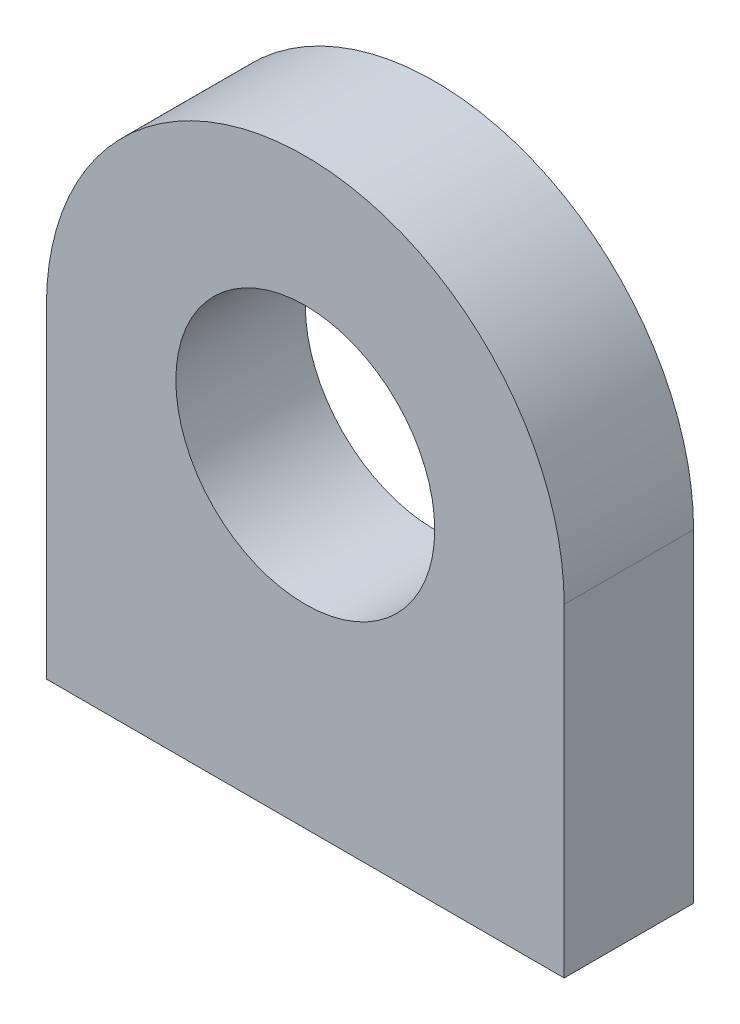
from build123d import *

# Parameters (mm, degrees)
CROQUIS1_R              = 4
SALIENTE_EXTRUIR1_DEPTH = 4


with BuildPart() as part:
    # Croquis1 → Saliente-Extruir1 (new body)
    with BuildSketch(Plane.XY):
        with BuildLine():
            Line((-8, 0), (-8, -10))
            Line((-8, -10), (8, -10))
            Line((8, -10), (8, 0))
            ThreePointArc((8, 0), (0, 8), (-8, 0))
        make_face()
        Circle(CROQUIS1_R, mode=Mode.SUBTRACT)
    extrude(amount=SALIENTE_EXTRUIR1_DEPTH)


solid = part.part
